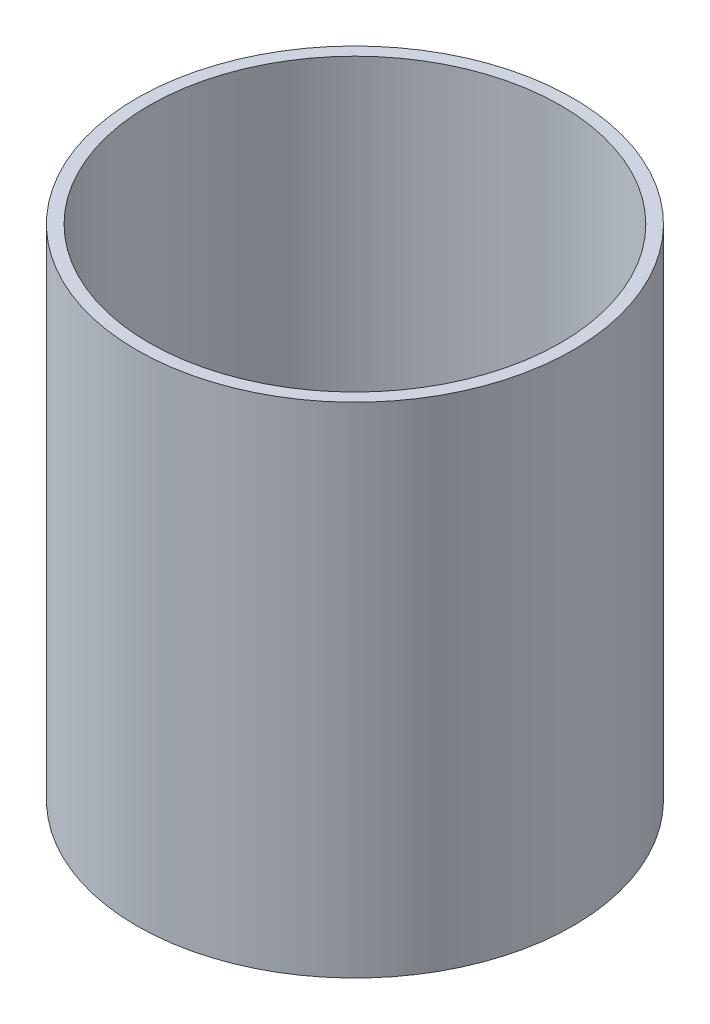
from build123d import *

# Parameters (mm, degrees)
SKETCH1_R           = 22.225
SKETCH1_R_2         = 20.955
BOSS_EXTRUDE1_DEPTH = 50.8


with BuildPart() as part:
    # Sketch1 → Boss-Extrude1 (new body)
    with BuildSketch(Plane(origin=(0, 0, 0), x_dir=(1, 0, 0), z_dir=(0, 1, 0))):
        Circle(SKETCH1_R)
        Circle(SKETCH1_R_2, mode=Mode.SUBTRACT)
    extrude(amount=BOSS_EXTRUDE1_DEPTH)


solid = part.part
